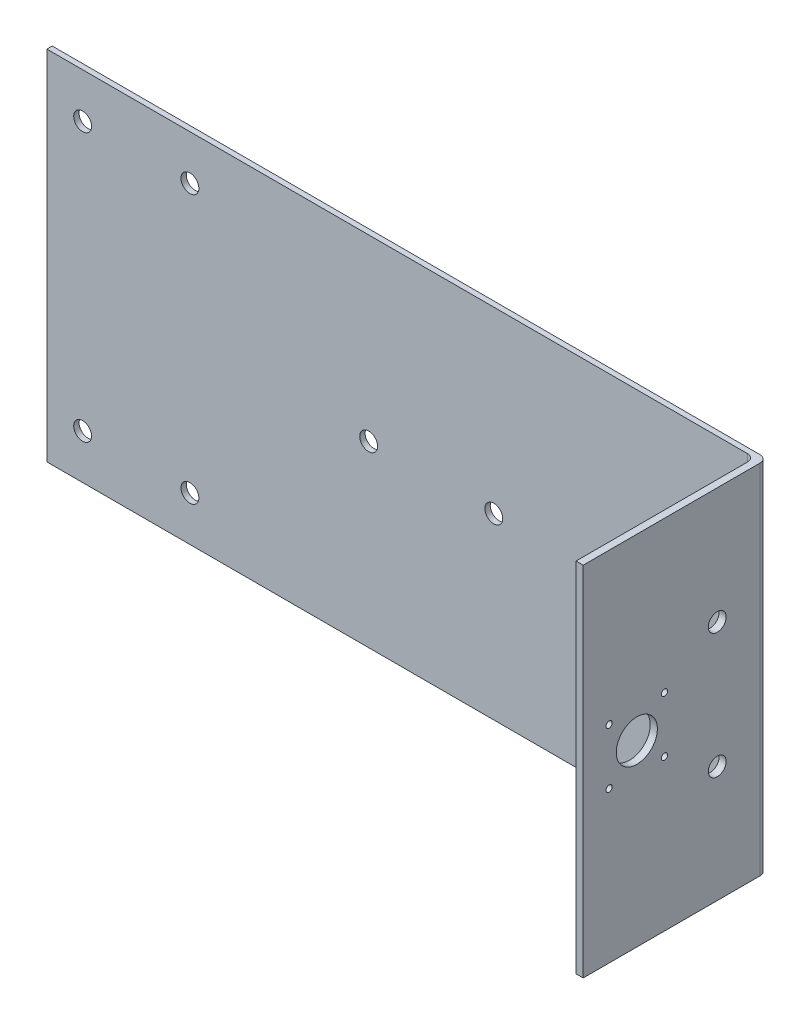
from build123d import *

# Parameters (mm, degrees)
SKETCH1_W           = 400
SKETCH1_H           = 200
BOSS_EXTRUDE1_DEPTH = 3
SKETCH2_R           = 5
CUT_EXTRUDE1_DEPTH  = 10
SKETCH3_W           = 4
SKETCH3_H           = 200
BOSS_EXTRUDE2_DEPTH = 90
FILLET2_R           = 4
SKETCH4_R           = 11.5
CUT_EXTRUDE2_DEPTH  = 90
SKETCH5_R           = 1.75
CUT_EXTRUDE3_DEPTH  = 90
SKETCH6_R           = 5
CUT_EXTRUDE4_DEPTH  = 15
SKETCH7_W           = 4
SKETCH7_H           = 200
BOSS_EXTRUDE3_DEPTH = 10


with BuildPart() as part:
    # Sketch1 → Boss-Extrude1 (new body)
    with BuildSketch(Plane.XY):
        Rectangle(SKETCH1_W, SKETCH1_H)
    extrude(amount=BOSS_EXTRUDE1_DEPTH)

    # Sketch2 → Cut-Extrude1 (cut)
    with BuildSketch(Plane(origin=(0, 0, 0), x_dir=(-1, 0, 0), z_dir=(0, 0, -1))):
        with Locations((-120, 0)):
            Circle(SKETCH2_R)
        with Locations((-50, 0)):
            Circle(SKETCH2_R)
        with Locations((20, 0)):
            Circle(SKETCH2_R)
        with Locations((180, -75)):
            Circle(SKETCH2_R)
        with Locations((120, -75)):
            Circle(SKETCH2_R)
        with Locations((120, 75)):
            Circle(SKETCH2_R)
        with Locations((180, 75)):
            Circle(SKETCH2_R)
    extrude(amount=-CUT_EXTRUDE1_DEPTH, mode=Mode.SUBTRACT)

    # Sketch3 → Boss-Extrude2 (add)
    with BuildSketch(Plane.XY.offset(3)):
        with Locations((198, 0)):
            Rectangle(SKETCH3_W, SKETCH3_H)
    extrude(amount=BOSS_EXTRUDE2_DEPTH)

    # Fillet2
    fillet2_edges = [part.edges().sort_by_distance(p)[0] for p in [
        (196, 0, 3),
        (200, 0, 0),
    ]]
    fillet(fillet2_edges, radius=FILLET2_R)

    # Sketch4 → Cut-Extrude2 (cut)
    with BuildSketch(Plane(origin=(200, 0, 0), x_dir=(0, 0, -1), z_dir=(1, 0, 0))):
        with Locations((-73, 0)):
            Circle(SKETCH4_R)
    extrude(amount=-CUT_EXTRUDE2_DEPTH, mode=Mode.SUBTRACT)

    # Sketch5 → Cut-Extrude3 (cut)
    with BuildSketch(Plane(origin=(200, 0, 0), x_dir=(0, 0, -1), z_dir=(1, 0, 0))):
        with Locations((-57.5, 15.5)):
            Circle(SKETCH5_R)
        with Locations((-57.5, -15.5)):
            Circle(SKETCH5_R)
        with Locations((-88.5, -15.5)):
            Circle(SKETCH5_R)
        with Locations((-88.5, 15.5)):
            Circle(SKETCH5_R)
    extrude(amount=-CUT_EXTRUDE3_DEPTH, mode=Mode.SUBTRACT)

    # Sketch6 → Cut-Extrude4 (cut)
    with BuildSketch(Plane(origin=(200, 0, 0), x_dir=(0, 0, -1), z_dir=(1, 0, 0))):
        with Locations((-28, -35)):
            Circle(SKETCH6_R)
        with Locations((-28, 35)):
            Circle(SKETCH6_R)
    extrude(amount=-CUT_EXTRUDE4_DEPTH, mode=Mode.SUBTRACT)

    # Sketch7 → Boss-Extrude3 (add)
    with BuildSketch(Plane.XY.offset(93)):
        with Locations((198, 0)):
            Rectangle(SKETCH7_W, SKETCH7_H)
    extrude(amount=BOSS_EXTRUDE3_DEPTH)


solid = part.part
